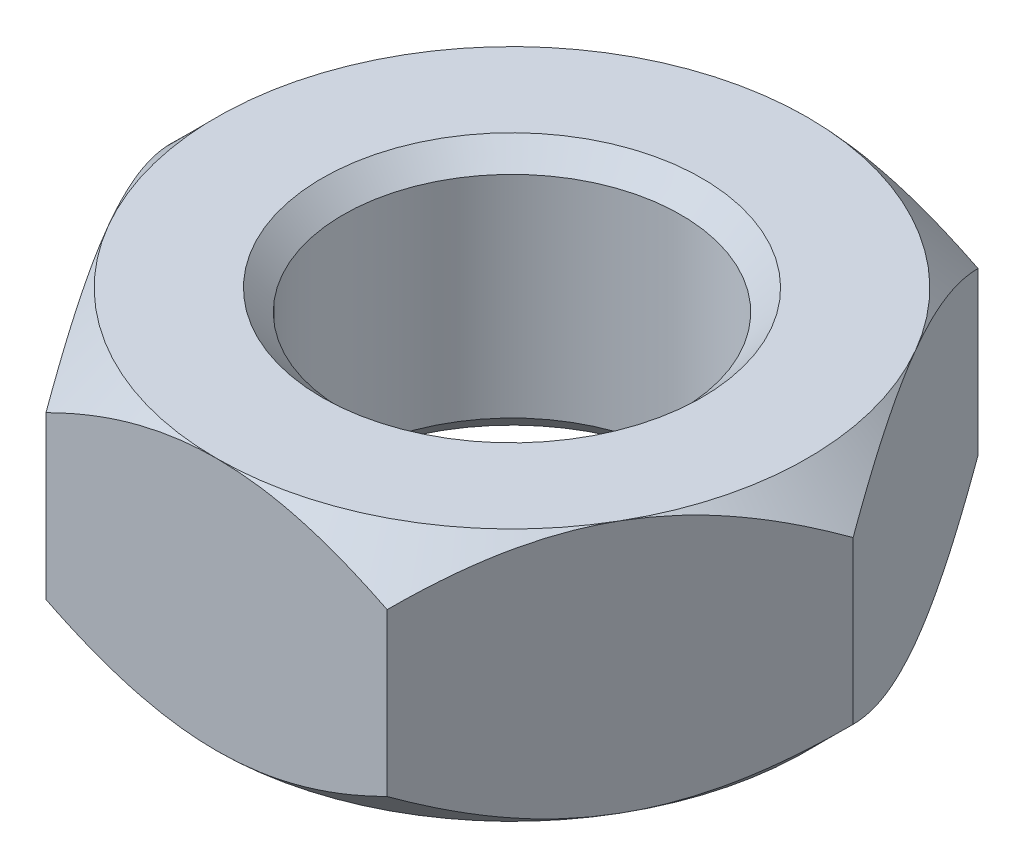
from build123d import *

# Parameters (mm, degrees)
SKETCH1_R           = 2
BOSS_EXTRUDE1_DEPTH = 3
CHAMFER2_SIZE       = 0.25


with BuildPart() as part:
    # Sketch1 → Boss-Extrude1 (new body)
    with BuildSketch(Plane(origin=(0, 0, 0), x_dir=(1, 0, 0), z_dir=(0, 1, 0))):
        Polygon((-2.020725942, -3.5), (2.020725942, -3.5), (4.041451884, 0), (2.020725942, 3.5), (-2.020725942, 3.5), (-4.041451884, 0), align=None)
        Circle(SKETCH1_R, mode=Mode.SUBTRACT)
    extrude(amount=BOSS_EXTRUDE1_DEPTH)

    # Sketch2 → Cut-Revolve1 (revolve, cut)
    with BuildSketch(Plane(origin=(0, 0, 0), x_dir=(0, 0, -1), z_dir=(1, 0, 0))):
        Polygon((3.5, 3), (4.55, 4.05), (4.55, 1.95), align=None)
        Polygon((4.55, 1.05), (3.5, 0), (4.55, -1.05), align=None)
    revolve(axis=Axis((0, 3, 0), (0, -1, 0)), mode=Mode.SUBTRACT)

    # Chamfer2
    chamfer2_edges = [part.edges().sort_by_distance(p)[0] for p in [
        (-2, 0, 0),
        (-2, 3, 0),
    ]]
    chamfer(chamfer2_edges, length=CHAMFER2_SIZE)


solid = part.part
